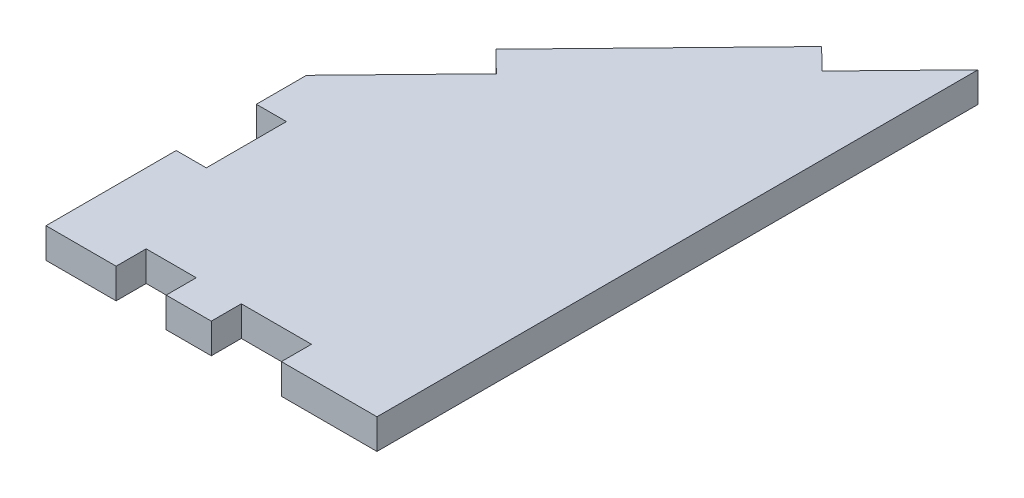
from build123d import *

# Parameters (mm, degrees)
BOSS_EXTRUDE1_DEPTH = 3


with BuildPart() as part:
    # Sketch1 → Boss-Extrude1 (new body)
    with BuildSketch(Plane(origin=(0, 0, 0), x_dir=(1, 0, 0), z_dir=(0, 1, 0))):
        Polygon((1571.171562964, -4116.173569386), (1571.171562964, -4111.173569386), (1580.516633244, -4101.556971641), (1578.365156574, -4099.466242548), (1594.39407962, -4082.971588082), (1596.54555629, -4085.062317175), (1604.211562964, -4077.173569386), (1604.211562964, -4137.173569386), (1594.671562964, -4137.173569386), (1594.671562964, -4134.173569386), (1587.671562964, -4134.173569386), (1587.671562964, -4137.173569386), (1583.171562964, -4137.173569386), (1583.171562964, -4134.173569386), (1578.171562964, -4134.173569386), (1578.171562964, -4137.173569386), (1571.171562964, -4137.173569386), (1571.171562964, -4124.173569386), (1574.171562964, -4124.173569386), (1574.171562964, -4116.173569386), align=None)
    extrude(amount=BOSS_EXTRUDE1_DEPTH)


solid = part.part
